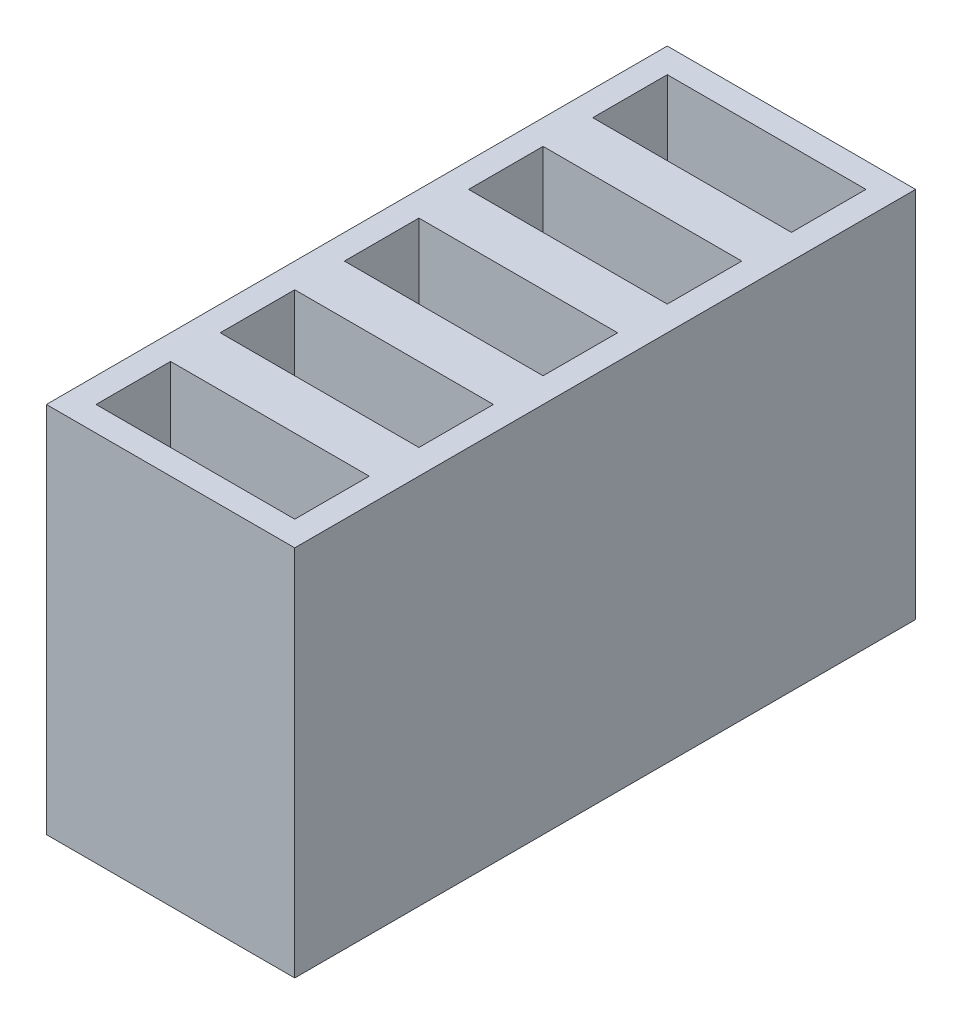
from build123d import *

# Parameters (mm, degrees)
CROQUIS1_W              = 20
CROQUIS1_H              = 50
SALIENTE_EXTRUIR1_DEPTH = 30
CROQUIS2_W              = 16
CROQUIS2_H              = 6
CORTAR_EXTRUIR1_DEPTH   = 25


with BuildPart() as part:
    # Croquis1 → Saliente-Extruir1 (new body)
    with BuildSketch(Plane(origin=(0, 0, 0), x_dir=(1, 0, 0), z_dir=(0, 1, 0))):
        with Locations((-37.210008549, -5.883213926)):
            Rectangle(CROQUIS1_W, CROQUIS1_H)
    extrude(amount=SALIENTE_EXTRUIR1_DEPTH)

    # Croquis2 → Cortar-Extruir1 (cut)
    with BuildSketch(Plane(origin=(0, 30, 0), x_dir=(1, 0, 0), z_dir=(0, 1, 0))):
        with Locations((-37.210008549, -25.883213926)):
            Rectangle(CROQUIS2_W, CROQUIS2_H)
        with Locations((-37.210008549, 4.116786074)):
            Rectangle(CROQUIS2_W, CROQUIS2_H)
        with Locations((-37.210008549, -15.883213926)):
            Rectangle(CROQUIS2_W, CROQUIS2_H)
        with Locations((-37.210008549, -5.883213926)):
            Rectangle(CROQUIS2_W, CROQUIS2_H)
        with Locations((-37.210008549, 14.116786074)):
            Rectangle(CROQUIS2_W, CROQUIS2_H)
    extrude(amount=-CORTAR_EXTRUIR1_DEPTH, mode=Mode.SUBTRACT)


solid = part.part
